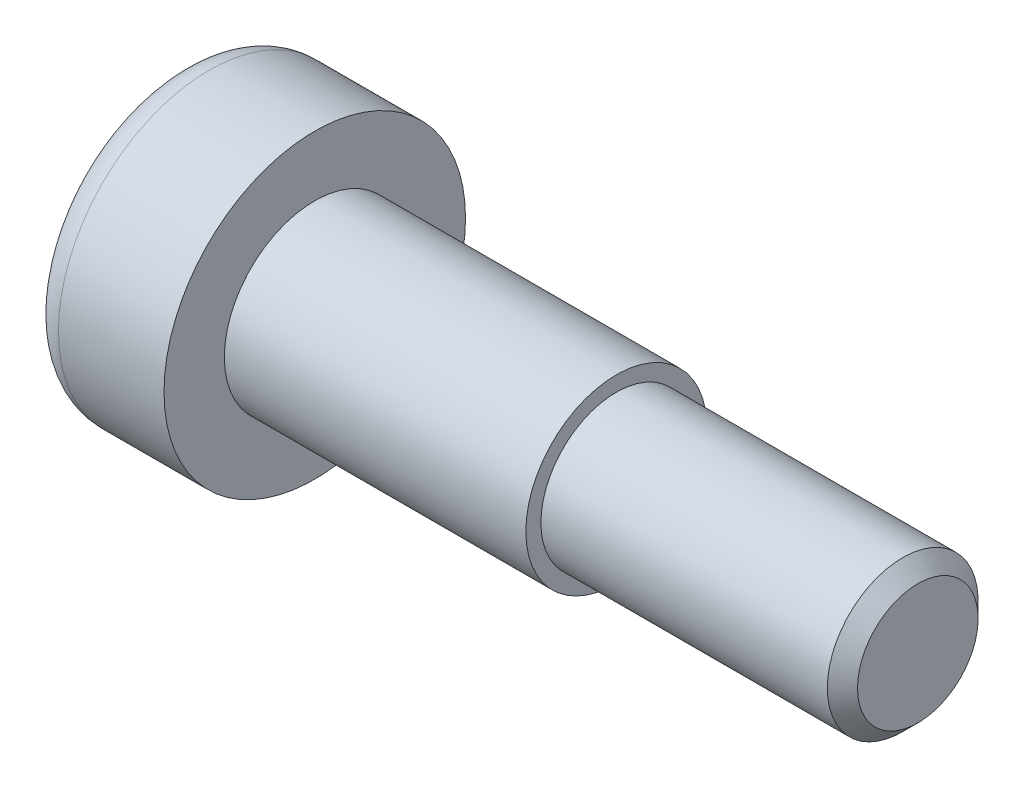
from build123d import *

# Parameters (mm, degrees)
CUT_EXTRUDE_1_DEPTH = 3
FILLET_1_R          = 1
CHAMFER_1_SIZE      = 0.5


with BuildPart() as part:
    # 草图1 → 旋转1 (revolve)
    with BuildSketch(Plane.XY):
        Polygon((0, 0), (0, 5), (4.5, 5), (4.5, 3), (14.5, 3), (14.5, 2.5), (24.5, 2.5), (24.5, 0), align=None)
    revolve(axis=Axis((0, 0, 0), (1, 0, 0)))

    # 草图2 → 切除-拉伸1 (cut)
    with BuildSketch(Plane.ZY):
        Polygon((0, 1.732050808), (-1.5, 0.866025404), (-1.5, -0.866025404), (0, -1.732050808), (1.5, -0.866025404), (1.5, 0.866025404), align=None)
    extrude(amount=-CUT_EXTRUDE_1_DEPTH, mode=Mode.SUBTRACT)

    # 圆角1
    fillet_1_edges = [part.edges().sort_by_distance(p)[0] for p in [
        (0, -5, 0),
    ]]
    fillet(fillet_1_edges, radius=FILLET_1_R)

    # 倒角1
    chamfer_1_edges = [part.edges().sort_by_distance(p)[0] for p in [
        (24.5, -2.5, 0),
    ]]
    chamfer(chamfer_1_edges, length=CHAMFER_1_SIZE)


solid = part.part
